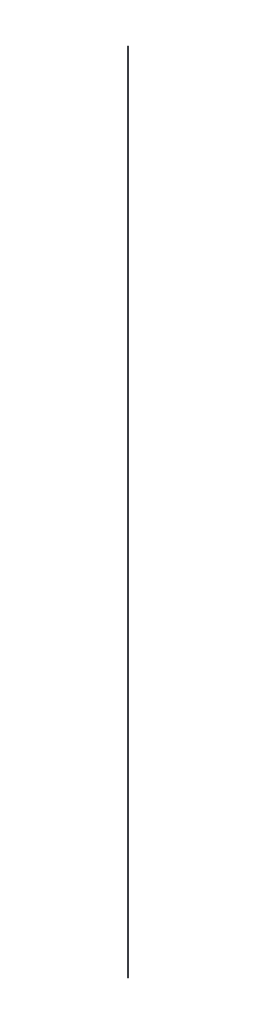
from build123d import *

# Parameters (mm, degrees)
SKETCH1_R           = 0.121522631
BOSS_EXTRUDE1_DEPTH = 250


with BuildPart() as part:
    # Sketch1 → Boss-Extrude1 (new body, symmetric)
    with BuildSketch(Plane(origin=(0, 0, 0), x_dir=(1, 0, 0), z_dir=(0, 1, 0))):
        Circle(SKETCH1_R)
    extrude(amount=BOSS_EXTRUDE1_DEPTH, both=True)


solid = part.part
